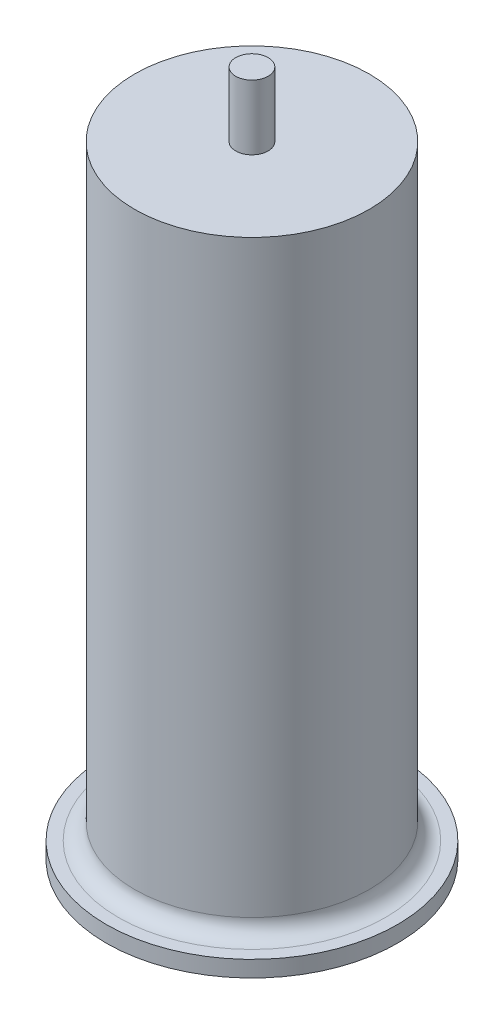
from build123d import *

# Parameters (mm, degrees)
SKETCH1_R           = 72.5
BOSS_EXTRUDE1_DEPTH = 384
SKETCH2_R           = 90
BOSS_EXTRUDE2_DEPTH = 10
FILLET1_R           = 10
SKETCH3_R           = 10
BOSS_EXTRUDE3_DEPTH = 40


with BuildPart() as part:
    # Sketch1 → Boss-Extrude1 (new body)
    with BuildSketch(Plane(origin=(0, 0, 0), x_dir=(1, 0, 0), z_dir=(0, 1, 0))):
        Circle(SKETCH1_R)
    extrude(amount=BOSS_EXTRUDE1_DEPTH)

    # Sketch2 → Boss-Extrude2 (add)
    with BuildSketch(Plane(origin=(0, 0, 0), x_dir=(1, 0, 0), z_dir=(0, 1, 0))):
        Circle(SKETCH2_R)
    extrude(amount=BOSS_EXTRUDE2_DEPTH)

    # Fillet1
    fillet1_edges = [part.edges().sort_by_distance(p)[0] for p in [
        (-72.5, 10, 0),
    ]]
    fillet(fillet1_edges, radius=FILLET1_R)

    # Sketch3 → Boss-Extrude3 (add)
    with BuildSketch(Plane(origin=(0, 384, 0), x_dir=(1, 0, 0), z_dir=(0, 1, 0))):
        Circle(SKETCH3_R)
    extrude(amount=BOSS_EXTRUDE3_DEPTH)


solid = part.part
